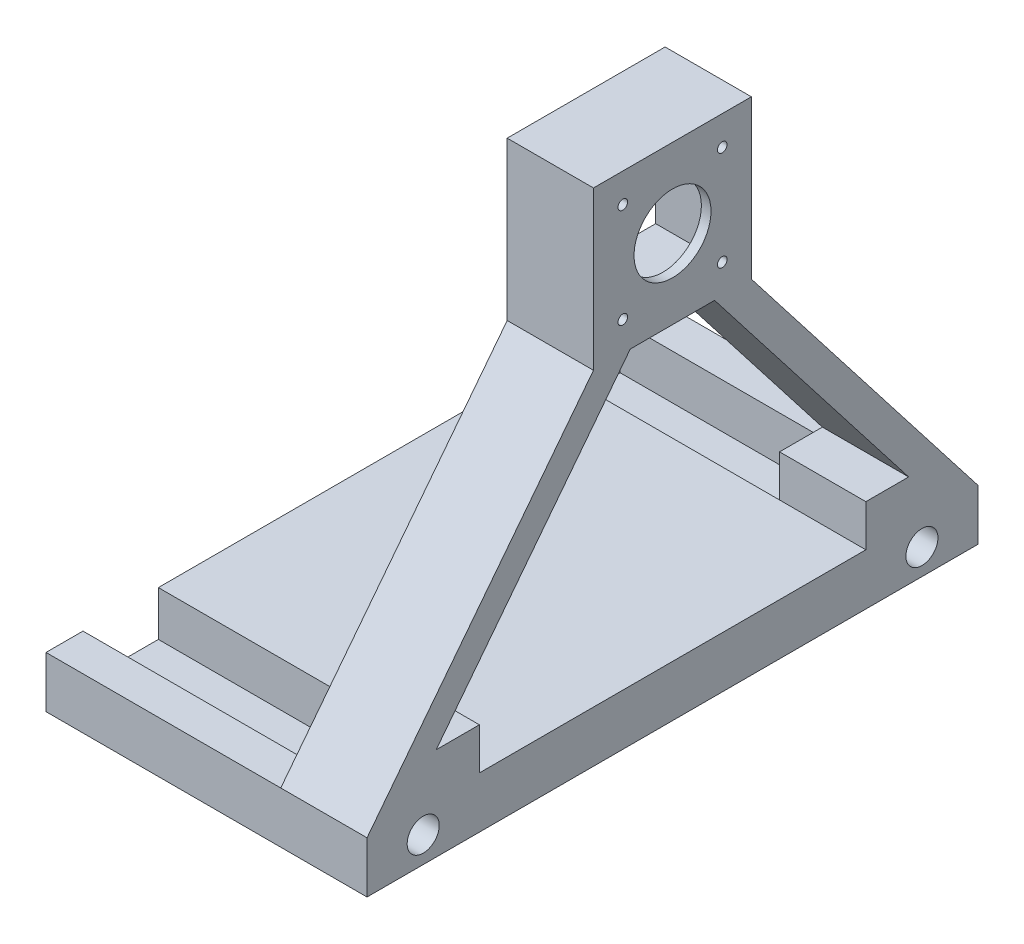
from build123d import *

# Parameters (mm, degrees)
SKETCH1_W                                     = 127
SKETCH1_H                                     = 190.5
BOSS_EXTRUDE1_DEPTH                           = 16
SKETCH3_W                                     = 73.2
SKETCH3_H                                     = 190.5
CUT_EXTRUDE2_DEPTH                            = 14
SKETCH6_W                                     = 73.2
SKETCH6_H                                     = 120.5
SKETCH6_H_2                                   = 11.470358649
SKETCH6_H_3                                   = 11.529641351
BOSS_EXTRUDE5_DEPTH                           = 14
SKETCH9_W                                     = 49.3
SKETCH9_H                                     = 49.3
SKETCH9_W_2                                   = 43.3
SKETCH9_H_2                                   = 43.3
BOSS_EXTRUDE7_DEPTH                           = 26.9
SKETCH9_5_W                                   = 43.3
SKETCH9_5_H                                   = 43.3
SKETCH9_5_W_2                                 = 31.3
SKETCH9_5_H_2                                 = 31.3
SKETCH9_5_R                                   = 12
BOSS_EXTRUDE8_DEPTH                           = 3
SKETCH10_W                                    = 43.3
SKETCH10_H                                    = 43.3
BOSS_EXTRUDE11_DEPTH                          = 26.9
SKETCH10_5_W                                  = 43.3
SKETCH10_5_H                                  = 43.3
SKETCH10_5_W_2                                = 31.3
SKETCH10_5_H_2                                = 31.3
SKETCH10_5_R                                  = 12
BOSS_EXTRUDE12_DEPTH                          = 3
SKETCH12_R                                    = 1.5
CUT_EXTRUDE4_DEPTH                            = 124
SKETCH13_W                                    = 26.9
SKETCH13_H                                    = 23.5
SKETCH13_H_2                                  = 23.559282703
SKETCH13_H_3                                  = 23.440717297
BOSS_EXTRUDE13_DEPTH                          = 13
CBORE_FOR_M4_PAN_HEAD_MACHINE_SCREW1_AT_COUNT = 2
CBORE_FOR_M4_PAN_HEAD_MACHINE_SCREW1_AT_PITCH = 13.45
CBORE_FOR_M4_PAN_HEAD_MACHINE_SCREW1_2_COUNT  = 2
CBORE_FOR_M4_PAN_HEAD_MACHINE_SCREW1_2_PITCH  = 86.65000507
CBORE_FOR_M4_PAN_HEAD_MACHINE_SCREW1_3_COUNT  = 2
CBORE_FOR_M4_PAN_HEAD_MACHINE_SCREW1_3_PITCH  = 100.100004389
CBORE_FOR_M4_PAN_HEAD_MACHINE_SCREW1_4_COUNT  = 2
CBORE_FOR_M4_PAN_HEAD_MACHINE_SCREW1_4_PITCH  = 167.16209619
CBORE_FOR_M4_PAN_HEAD_MACHINE_SCREW1_5_COUNT  = 2
CBORE_FOR_M4_PAN_HEAD_MACHINE_SCREW1_5_PITCH  = 159.472188492
CBORE_FOR_M4_PAN_HEAD_MACHINE_SCREW1_6_COUNT  = 2
CBORE_FOR_M4_PAN_HEAD_MACHINE_SCREW1_6_PITCH  = 133.877393172
CBORE_FOR_M4_PAN_HEAD_MACHINE_SCREW1_7_COUNT  = 2
CBORE_FOR_M4_PAN_HEAD_MACHINE_SCREW1_7_PITCH  = 134.551324417
CUT_EXTRUDE8_START                            = -127
SKETCH27_R                                    = 5
CUT_EXTRUDE8_DEPTH                            = 127
SPLIT1_SURFACE_1_BACK                         = 278.18
SPLIT1_SURFACE_1_DEPTH                        = 556.36


with BuildPart() as part:
    # Sketch1 → Boss-Extrude1 (new body)
    with BuildSketch(Plane(origin=(0, 0, 0), x_dir=(1, 0, 0), z_dir=(0, 1, 0))):
        with Locations((22.032491394, 64.602312685)):
            Rectangle(SKETCH1_W, SKETCH1_H)
    extrude(amount=BOSS_EXTRUDE1_DEPTH)

    # Sketch3 → Cut-Extrude2 (cut)
    with BuildSketch(Plane(origin=(0, 16, 0), x_dir=(1, 0, 0), z_dir=(0, 1, 0))):
        with Locations((22.032491394, 64.602312685)):
            Rectangle(SKETCH3_W, SKETCH3_H)
    extrude(amount=-CUT_EXTRUDE2_DEPTH, mode=Mode.SUBTRACT)

    # Sketch6 → Boss-Extrude5 (add)
    with BuildSketch(Plane(origin=(0, 2, 0), x_dir=(1, 0, 0), z_dir=(0, 1, 0))):
        with Locations((22.032491394, 64.631954036)):
            Rectangle(SKETCH6_W, SKETCH6_H)
        with Locations((22.032491394, 154.117133361)):
            Rectangle(SKETCH6_W, SKETCH6_H_2)
        with Locations((22.032491394, -24.88286664)):
            Rectangle(SKETCH6_W, SKETCH6_H_3)
    extrude(amount=BOSS_EXTRUDE5_DEPTH)

    # Sketch9 → Boss-Extrude7 (add)
    with BuildSketch(Plane.ZY.offset(41.467508606)):
        Polygon((-77.781954036, 106.934621953), (-89.252312685, 106.934621953), (-159.852312685, 16), (-148.381954036, 16), align=None)
        with Locations((-64.602312685, 131.584621953)):
            Rectangle(SKETCH9_W, SKETCH9_H)
        with Locations((-64.602312685, 131.584621953)):
            Rectangle(SKETCH9_W_2, SKETCH9_H_2, mode=Mode.SUBTRACT)
        Polygon((30.647687315, 16), (-39.952312685, 106.934621953), (-51.481954036, 106.934621953), (19.118045964, 16), align=None)
    extrude(amount=-BOSS_EXTRUDE7_DEPTH)

    # Sketch9_5 → Boss-Extrude8 (add)
    with BuildSketch(Plane.ZY.offset(41.467508606)):
        with Locations((-64.602312685, 131.584621953)):
            Rectangle(SKETCH9_5_W, SKETCH9_5_H)
        with Locations((-64.602312685, 131.584621953)):
            Rectangle(SKETCH9_5_W_2, SKETCH9_5_H_2, mode=Mode.SUBTRACT)
        with Locations((-64.602312685, 131.584621953)):
            Rectangle(SKETCH9_5_W_2, SKETCH9_5_H_2)
        with Locations((-64.602312685, 131.584621953)):
            Circle(SKETCH9_5_R, mode=Mode.SUBTRACT)
    extrude(amount=-BOSS_EXTRUDE8_DEPTH)

    # Sketch10 → Boss-Extrude11 (add)
    with BuildSketch(Plane(origin=(85.532491394, 0, 0), x_dir=(0, 0, -1), z_dir=(1, 0, 0))):
        Polygon((89.192671333, 156.174980602), (39.952312685, 156.174980602), (39.952312685, 106.934621953), (-30.647687315, 16), (-19.177328667, 16), (51.422671333, 106.934621953), (77.722671333, 106.934621953), (148.322671333, 16), (159.792671333, 16), (89.192671333, 106.934621953), align=None)
        with Locations((64.602312685, 131.584621953)):
            Rectangle(SKETCH10_W, SKETCH10_H, mode=Mode.SUBTRACT)
    extrude(amount=-BOSS_EXTRUDE11_DEPTH)

    # Sketch10_5 → Boss-Extrude12 (add)
    with BuildSketch(Plane(origin=(85.532491394, 0, 0), x_dir=(0, 0, -1), z_dir=(1, 0, 0))):
        with Locations((64.602312685, 131.584621953)):
            Rectangle(SKETCH10_5_W, SKETCH10_5_H)
        with Locations((64.602312685, 131.584621953)):
            Rectangle(SKETCH10_5_W_2, SKETCH10_5_H_2, mode=Mode.SUBTRACT)
        with Locations((64.602312685, 131.584621953)):
            Rectangle(SKETCH10_5_W_2, SKETCH10_5_H_2)
        with Locations(Location((64.602312685, 131.584621953, 0), (0, 0, 180))):
            Circle(SKETCH10_5_R, mode=Mode.SUBTRACT)
    extrude(amount=-BOSS_EXTRUDE12_DEPTH)

    # Sketch12 → Cut-Extrude4 (cut)
    with BuildSketch(Plane(origin=(-38.467508606, 0, 0), x_dir=(0, 0, -1), z_dir=(1, 0, 0))):
        with Locations(Location((80.102312685, 147.084621953, 0), (0, 0, 180))):
            Circle(SKETCH12_R)
        with Locations(Location((49.102312685, 147.084621953, 0), (0, 0, 180))):
            Circle(SKETCH12_R)
        with Locations(Location((49.102312685, 116.084621953, 0), (0, 0, 180))):
            Circle(SKETCH12_R)
        with Locations(Location((80.102312685, 116.084621953, 0), (0, 0, 180))):
            Circle(SKETCH12_R)
    extrude(amount=CUT_EXTRUDE4_DEPTH, mode=Mode.SUBTRACT)

    # Sketch13 → Boss-Extrude13 (add)
    with BuildSketch(Plane(origin=(0, 16, 0), x_dir=(1, 0, 0), z_dir=(0, 1, 0))):
        with Locations((-28.017508606, 136.631954036)):
            Rectangle(SKETCH13_W, SKETCH13_H)
        with Locations((-28.017508606, -7.368045964)):
            Rectangle(SKETCH13_W, SKETCH13_H)
        with Locations((72.082491394, -7.397687316)):
            Rectangle(SKETCH13_W, SKETCH13_H_2)
        with Locations((72.082491394, 136.602312685)):
            Rectangle(SKETCH13_W, SKETCH13_H_3)
    extrude(amount=BOSS_EXTRUDE13_DEPTH)

    # Sketch24 → CBORE for M4 Pan Head Machine Screw1 (revolve, cut)
    with BuildSketch(Plane(origin=(-21.292508606, 0, 2.321563226), x_dir=(0, 0, -1), z_dir=(1, 0, 0))):
        Polygon((0, 0), (0, 26.291850331), (2.15, 25), (2.15, 3.1), (4.5, 3.1), (4.5, 0.046044272), (4.525, 0), align=None)
    cbore_for_m4_pan_head_machine_screw1 = revolve(axis=Axis((-21.292508606, -6.35, 2.321563226), (0, 1, 0)), mode=Mode.SUBTRACT)

    # CBORE for M4 Pan Head Machine Screw1 at: CBORE for M4 Pan Head Machine Screw1 ×2
    with Locations(*[(-i * CBORE_FOR_M4_PAN_HEAD_MACHINE_SCREW1_AT_PITCH, 0, 0) for i in range(1, CBORE_FOR_M4_PAN_HEAD_MACHINE_SCREW1_AT_COUNT)]):
        add(cbore_for_m4_pan_head_machine_screw1, mode=Mode.SUBTRACT)

    # CBORE for M4 Pan Head Machine Screw1 2: CBORE for M4 Pan Head Machine Screw1 ×2
    with Locations(*[Vector(0.9999999414901701, 0, 0.00034208135925630124) * (i * CBORE_FOR_M4_PAN_HEAD_MACHINE_SCREW1_2_PITCH) for i in range(1, CBORE_FOR_M4_PAN_HEAD_MACHINE_SCREW1_2_COUNT)]):
        add(cbore_for_m4_pan_head_machine_screw1, mode=Mode.SUBTRACT)

    # CBORE for M4 Pan Head Machine Screw1 3: CBORE for M4 Pan Head Machine Screw1 ×2
    with Locations(*[Vector(0.9999999561572464, 0, 0.0002961173847583374) * (i * CBORE_FOR_M4_PAN_HEAD_MACHINE_SCREW1_3_PITCH) for i in range(1, CBORE_FOR_M4_PAN_HEAD_MACHINE_SCREW1_3_COUNT)]):
        add(cbore_for_m4_pan_head_machine_screw1, mode=Mode.SUBTRACT)

    # CBORE for M4 Pan Head Machine Screw1 4: CBORE for M4 Pan Head Machine Screw1 ×2
    with Locations(*[Vector(0.5988199614729853, 0, -0.8008836705424156) * (i * CBORE_FOR_M4_PAN_HEAD_MACHINE_SCREW1_4_PITCH) for i in range(1, CBORE_FOR_M4_PAN_HEAD_MACHINE_SCREW1_4_COUNT)]):
        add(cbore_for_m4_pan_head_machine_screw1, mode=Mode.SUBTRACT)

    # CBORE for M4 Pan Head Machine Screw1 5: CBORE for M4 Pan Head Machine Screw1 ×2
    with Locations(*[Vector(0.5433549311591849, 0, -0.8395030784845268) * (i * CBORE_FOR_M4_PAN_HEAD_MACHINE_SCREW1_5_PITCH) for i in range(1, CBORE_FOR_M4_PAN_HEAD_MACHINE_SCREW1_5_COUNT)]):
        add(cbore_for_m4_pan_head_machine_screw1, mode=Mode.SUBTRACT)

    # CBORE for M4 Pan Head Machine Screw1 6: CBORE for M4 Pan Head Machine Screw1 ×2
    with Locations(*[(0, 0, -i * CBORE_FOR_M4_PAN_HEAD_MACHINE_SCREW1_6_PITCH) for i in range(1, CBORE_FOR_M4_PAN_HEAD_MACHINE_SCREW1_6_COUNT)]):
        add(cbore_for_m4_pan_head_machine_screw1, mode=Mode.SUBTRACT)

    # CBORE for M4 Pan Head Machine Screw1 7: CBORE for M4 Pan Head Machine Screw1 ×2
    with Locations(*[Vector(-0.09996185513764777, 0, -0.9949912700709691) * (i * CBORE_FOR_M4_PAN_HEAD_MACHINE_SCREW1_7_PITCH) for i in range(1, CBORE_FOR_M4_PAN_HEAD_MACHINE_SCREW1_7_COUNT)]):
        add(cbore_for_m4_pan_head_machine_screw1, mode=Mode.SUBTRACT)

    # Sketch27 → Cut-Extrude8 (cut)
    with BuildSketch(Plane.ZY.offset(41.467508606).offset(CUT_EXTRUDE8_START)):
        with Locations((-142.36713336, 8)):
            Circle(SKETCH27_R)
        with Locations((13.13286664, 8.093964388)):
            Circle(SKETCH27_R)
    extrude(amount=CUT_EXTRUDE8_DEPTH, mode=Mode.SUBTRACT)

    # Split1: cut with a surface, the side it looks to stays
    # Split1 surface: a surface, the sketch's curves swept straight by 556.36 mm
    with BuildLine(Plane.XY.offset(30.647687315).offset(-SPLIT1_SURFACE_1_BACK), mode=Mode.PRIVATE) as split1_surface_1_path:
        Line((-14.567508606, 16), (-14.567508606, 0))
    split1_surface_1 = Shell.extrude(split1_surface_1_path.wire(), (0 * SPLIT1_SURFACE_1_DEPTH, 0 * SPLIT1_SURFACE_1_DEPTH, 1 * SPLIT1_SURFACE_1_DEPTH))
    split(bisect_by=split1_surface_1, keep=Keep.TOP)


solid = part.part
